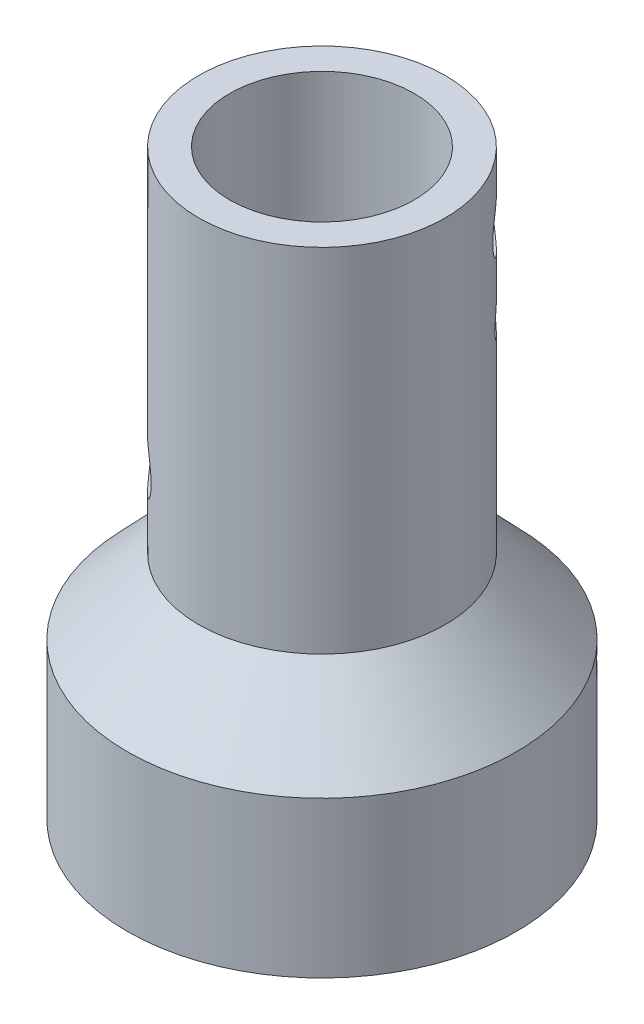
from build123d import *

# Parameters (mm, degrees)
SKETCH2_R          = 1.65
CUT_EXTRUDE1_DEPTH = 10
SKETCH4_R          = 1.625
SKETCH4_R_2        = 3
SKETCH4_R_3        = 1.9
CUT_EXTRUDE2_DEPTH = 78.805028758
SKETCH4_3_R        = 3
CUT_EXTRUDE3_DEPTH = 78.805028909


with BuildPart() as part:
    # Sketch1 → Revolve1 (revolve)
    with BuildSketch(Plane.XY):
        Polygon((11.15, 20.4), (11.15, 70.35), (14.9, 70.35), (14.9, 27.8), (23.5, 18.8), (23.5, 0), (14.225, 0), (14.225, 20.4), align=None)
    revolve(axis=Axis((0, 0, 0), (0, 1, 0)))

    # Sketch2 → Cut-Extrude1 (cut)
    with BuildSketch(Plane.XZ):
        with Locations((0, 19.625)):
            Circle(SKETCH2_R)
        with Locations((0, -19.625)):
            Circle(SKETCH2_R)
        with Locations((-19.625, 0)):
            Circle(SKETCH2_R)
        with Locations((19.625, 0)):
            Circle(SKETCH2_R)
    extrude(amount=-CUT_EXTRUDE1_DEPTH, mode=Mode.SUBTRACT)

    # Sketch4 → Cut-Extrude2 (cut, through all)
    with BuildSketch(Plane(origin=(0, 0, 0), x_dir=(0, -1, 0), z_dir=(-0.7071067811865488, 0, 0.7071067811865464))):
        with Locations((-16.875, 0)):
            Circle(SKETCH4_R)
        with Locations((-62.35, 0)):
            Circle(SKETCH4_R_2)
        with Locations((-52.45, 0)):
            Circle(SKETCH4_R_3)
    extrude(amount=-CUT_EXTRUDE2_DEPTH, mode=Mode.SUBTRACT)

    # Sketch4_3 → Cut-Extrude3 (cut, through all)
    with BuildSketch(Plane(origin=(0, 0, 0), x_dir=(0, -1, 0), z_dir=(-0.7071067811865488, 0, 0.7071067811865464))):
        with Locations((-37.15, 0)):
            Circle(SKETCH4_3_R)
    extrude(amount=CUT_EXTRUDE3_DEPTH, mode=Mode.SUBTRACT)


solid = part.part
